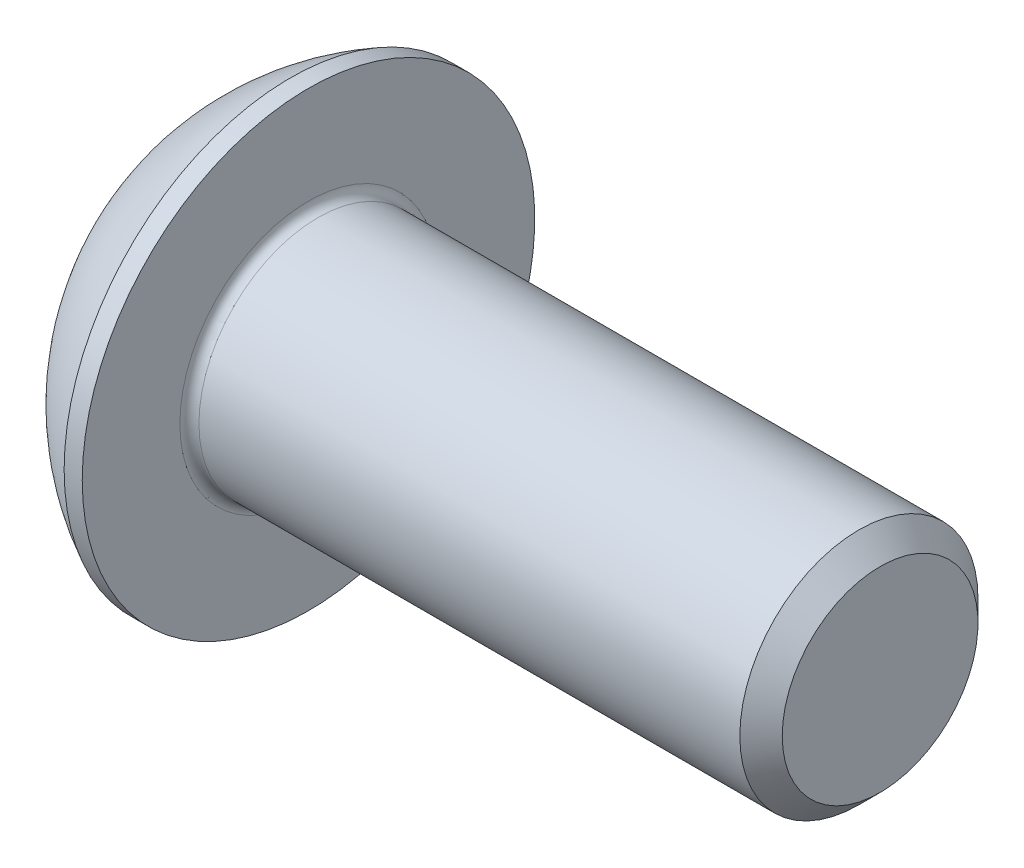
from build123d import *

# Parameters (mm, degrees)
FILLET1_R   = 0.2
HEX_2_DEPTH = 1.56


with BuildPart() as part:
    # BodySke → BaseBody (revolve)
    with BuildSketch(Plane.XY):
        with BuildLine():
            Line((14.75, 0), (14.75, 2.055))
            Line((14.75, 2.055), (14.305, 2.5))
            Line((14.305, 2.5), (2.75, 2.5))
            Line((2.75, 2.5), (2.75, 4.75))
            Line((2.75, 4.75), (2.37, 4.75))
            ThreePointArc((2.37, 4.75), (0.992680215, 3.754414901), (0, 2.375))
            Line((0, 2.375), (0, 0))
            Line((0, 0), (14.75, 0))
        make_face()
    revolve(axis=Axis((0, 0, 0), (1, 0, 0)))

    # Fillet1
    fillet1_edges = [part.edges().sort_by_distance(p)[0] for p in [
        (2.75, -2.5, 0),
    ]]
    fillet(fillet1_edges, radius=FILLET1_R)

    # Sketch2 → PreBroach (revolve, cut)
    with BuildSketch(Plane.XY):
        Polygon((0, 1.5), (1.56, 1.5), (2.426025404, 0), (0, 0), align=None)
    revolve(axis=Axis((0, 0, 0), (1, 0, 0)), mode=Mode.SUBTRACT)

    # Sketch3 → Hex 2 (cut)
    with BuildSketch(Plane(origin=(0, 0, 0), x_dir=(0, 0, -1), z_dir=(1, 0, 0))):
        Polygon((-1.5, -0.866025404), (-1.5, 0.866025404), (0, 1.732050808), (1.5, 0.866025404), (1.5, -0.866025404), (0, -1.732050808), align=None)
    extrude(amount=HEX_2_DEPTH, mode=Mode.SUBTRACT)


solid = part.part
